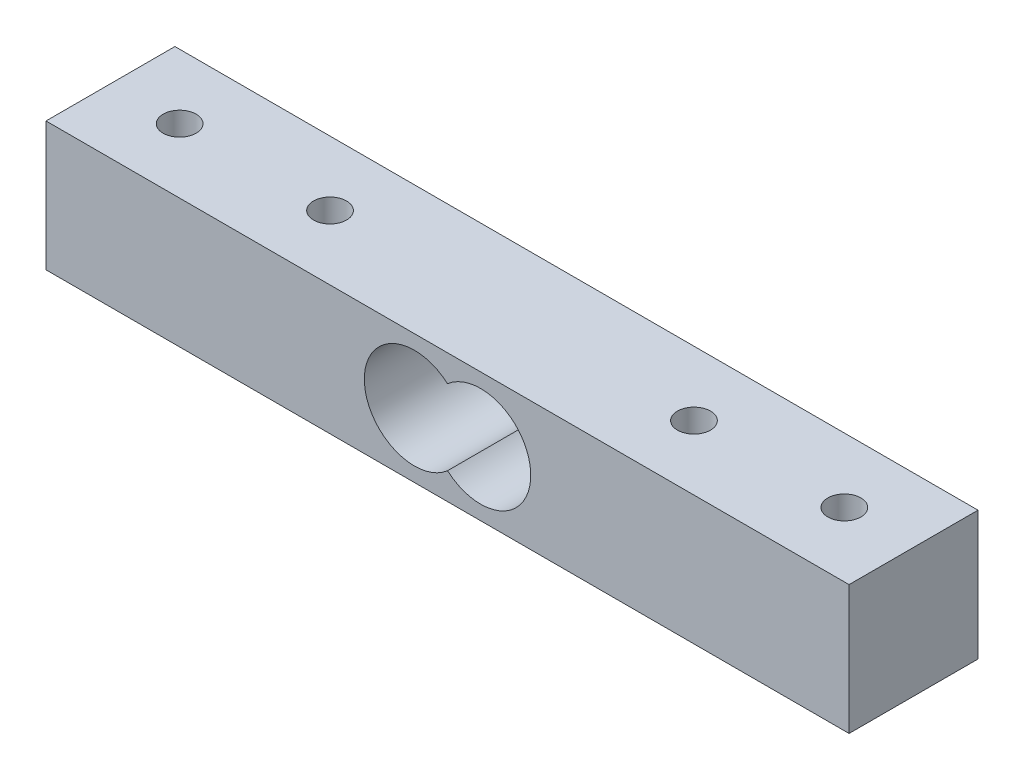
from build123d import *

# Parameters (mm, degrees)
IZIM1_W                     = 80.1
IZIM1_H                     = 12.86
Y_KSEKLIK_EKSTR_ZYON2_DEPTH = 6.43
M4_TAPPED_HOLE1_AT_2_COUNT  = 2
M4_TAPPED_HOLE1_AT_2_PITCH  = 15
M4_TAPPED_HOLE1_AT_3_COUNT  = 2
M4_TAPPED_HOLE1_AT_3_PITCH  = 51.3
M4_TAPPED_HOLE1_AT_4_COUNT  = 2
M4_TAPPED_HOLE1_AT_4_PITCH  = 66.3


with BuildPart() as part:
    # Çizim1 → Yükseklik-Ekstrüzyon2 (new body, symmetric)
    with BuildSketch(Plane.XY):
        Rectangle(IZIM1_W, IZIM1_H)
        with BuildLine():
            ThreePointArc((0, 3.756327994), (-8.3, 0), (0, -3.756327994))
            ThreePointArc((0, -3.756327994), (8.3, 0), (0, 3.756327994))
        make_face(mode=Mode.SUBTRACT)
    extrude(amount=Y_KSEKLIK_EKSTR_ZYON2_DEPTH, both=True)

    # Çizim8 → M4 Tapped Hole1 (revolve, cut)
    with BuildSketch(Plane(origin=(-33.15, 6.43, 0), x_dir=(0, 0, 1), z_dir=(1, 0, 0))):
        Polygon((0, 0), (0, 12.86), (2.025, 12.86), (1.65, 12.485), (1.65, 0), align=None)
    m4_tapped_hole1 = revolve(axis=Axis((-33.15, 12.78, 0), (0, -1, 0)), mode=Mode.SUBTRACT)

    # M4 Tapped Hole1 at 2: M4 Tapped Hole1 ×2
    with Locations(*[(i * M4_TAPPED_HOLE1_AT_2_PITCH, 0, 0) for i in range(1, M4_TAPPED_HOLE1_AT_2_COUNT)]):
        add(m4_tapped_hole1, mode=Mode.SUBTRACT)

    # M4 Tapped Hole1 at 3: M4 Tapped Hole1 ×2
    with Locations(*[(i * M4_TAPPED_HOLE1_AT_3_PITCH, 0, 0) for i in range(1, M4_TAPPED_HOLE1_AT_3_COUNT)]):
        add(m4_tapped_hole1, mode=Mode.SUBTRACT)

    # M4 Tapped Hole1 at 4: M4 Tapped Hole1 ×2
    with Locations(*[(i * M4_TAPPED_HOLE1_AT_4_PITCH, 0, 0) for i in range(1, M4_TAPPED_HOLE1_AT_4_COUNT)]):
        add(m4_tapped_hole1, mode=Mode.SUBTRACT)


solid = part.part
